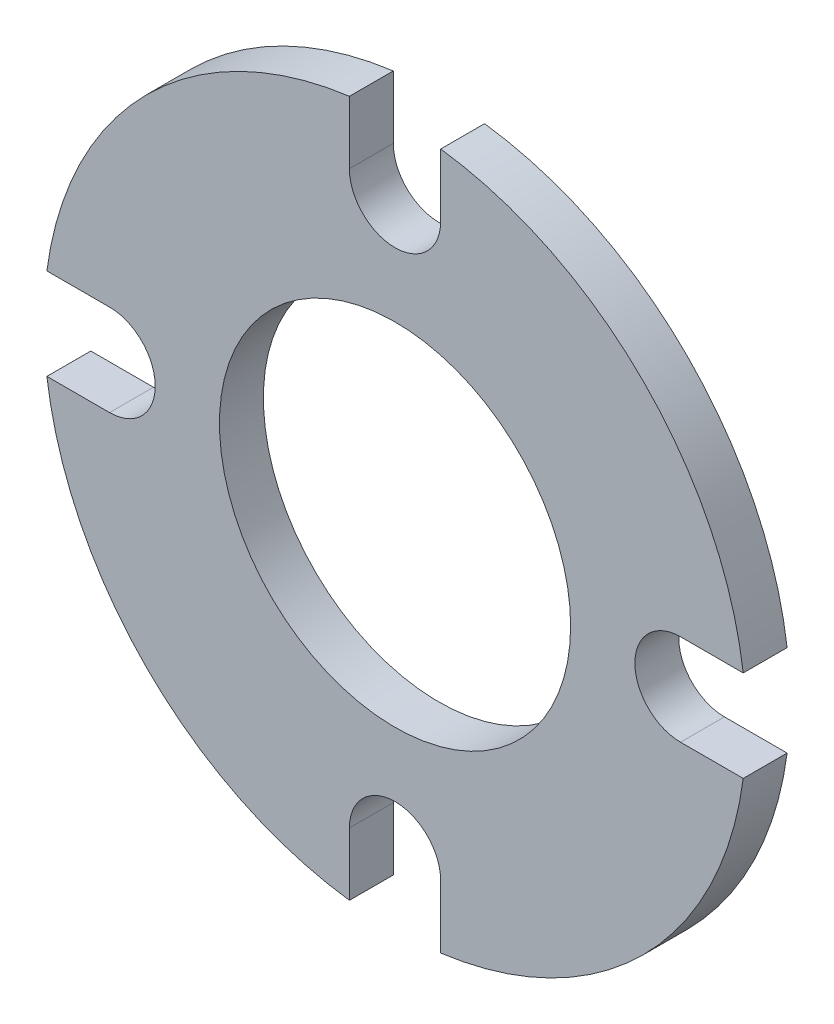
from build123d import *

# Parameters (mm, degrees)
SKETCH1_R           = 0.5
BOSS_EXTRUDE1_DEPTH = 0.125


with BuildPart() as part:
    # Sketch1 → Boss-Extrude1 (new body)
    with BuildSketch(Plane.XY):
        with BuildLine():
            Line((-0.813, 0.13), (-0.991513994, 0.13))
            ThreePointArc((-0.991513994, 0.13), (-0.707106781, 0.707106781), (-0.13, 0.991513994))
            Line((-0.13, 0.991513994), (-0.13, 0.813))
            ThreePointArc((-0.13, 0.813), (0, 0.683), (0.13, 0.813))
            Line((0.13, 0.813), (0.13, 0.991513994))
            ThreePointArc((0.13, 0.991513994), (0.707106781, 0.707106781), (0.991513994, 0.13))
            Line((0.991513994, 0.13), (0.813, 0.13))
            ThreePointArc((0.813, 0.13), (0.683, 0), (0.813, -0.13))
            Line((0.813, -0.13), (0.991513994, -0.13))
            ThreePointArc((0.991513994, -0.13), (0.707106781, -0.707106781), (0.13, -0.991513994))
            Line((0.13, -0.991513994), (0.13, -0.813))
            ThreePointArc((0.13, -0.813), (0, -0.683), (-0.13, -0.813))
            Line((-0.13, -0.813), (-0.13, -0.991513994))
            ThreePointArc((-0.13, -0.991513994), (-0.707106781, -0.707106781), (-0.991513994, -0.13))
            Line((-0.991513994, -0.13), (-0.813, -0.13))
            ThreePointArc((-0.813, -0.13), (-0.683, 0), (-0.813, 0.13))
        make_face()
        Circle(SKETCH1_R, mode=Mode.SUBTRACT)
    extrude(amount=BOSS_EXTRUDE1_DEPTH)


solid = part.part
